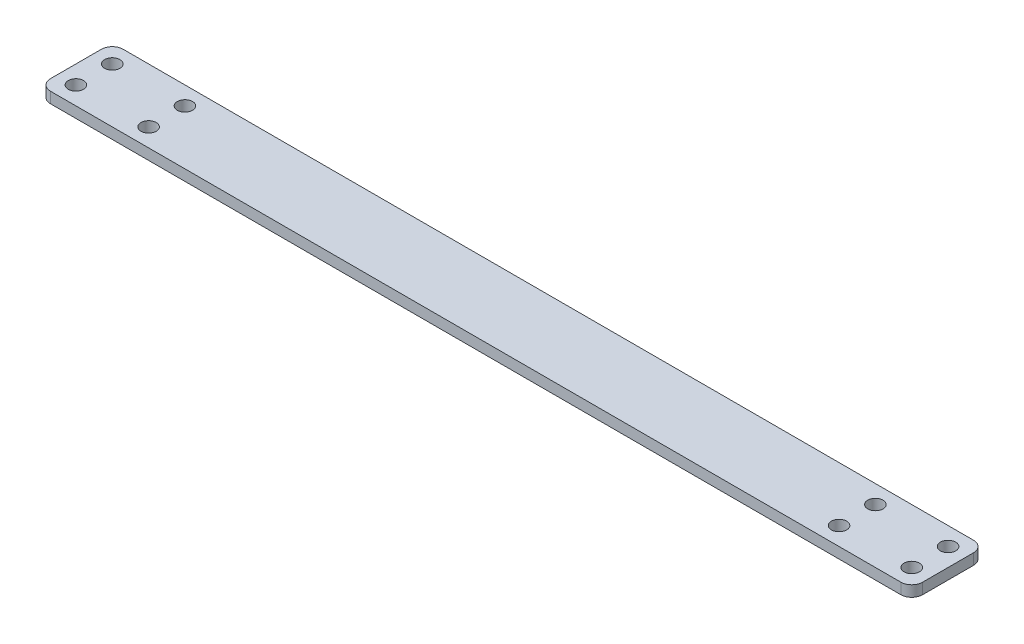
from build123d import *

# Parameters (mm, degrees)
SKETCH_2_W      = 240
SKETCH_2_H      = 20
SKETCH_2_R      = 2.1
EXTRUDE_1_DEPTH = 3
FILLET_1_R      = 3


with BuildPart() as part:
    # 草图2 → 凸台-拉伸1 (new body)
    with BuildSketch(Plane(origin=(0, 0, 0), x_dir=(1, 0, 0), z_dir=(0, 1, 0))):
        Rectangle(SKETCH_2_W, SKETCH_2_H)
        with Locations((-115, 5)):
            Circle(SKETCH_2_R, mode=Mode.SUBTRACT)
        with Locations((-95, 5)):
            Circle(SKETCH_2_R, mode=Mode.SUBTRACT)
        with Locations((-95, -5)):
            Circle(SKETCH_2_R, mode=Mode.SUBTRACT)
        with Locations((-115, -5)):
            Circle(SKETCH_2_R, mode=Mode.SUBTRACT)
        with Locations((115, -5)):
            Circle(SKETCH_2_R, mode=Mode.SUBTRACT)
        with Locations((95, -5)):
            Circle(SKETCH_2_R, mode=Mode.SUBTRACT)
        with Locations((95, 5)):
            Circle(SKETCH_2_R, mode=Mode.SUBTRACT)
        with Locations((115, 5)):
            Circle(SKETCH_2_R, mode=Mode.SUBTRACT)
    extrude(amount=EXTRUDE_1_DEPTH)

    # 圆角1
    fillet_1_edges = [part.edges().sort_by_distance(p)[0] for p in [
        (120, 1.5, 10),
        (-120, 1.5, 10),
        (-120, 1.5, -10),
        (120, 1.5, -10),
    ]]
    fillet(fillet_1_edges, radius=FILLET_1_R)


solid = part.part
